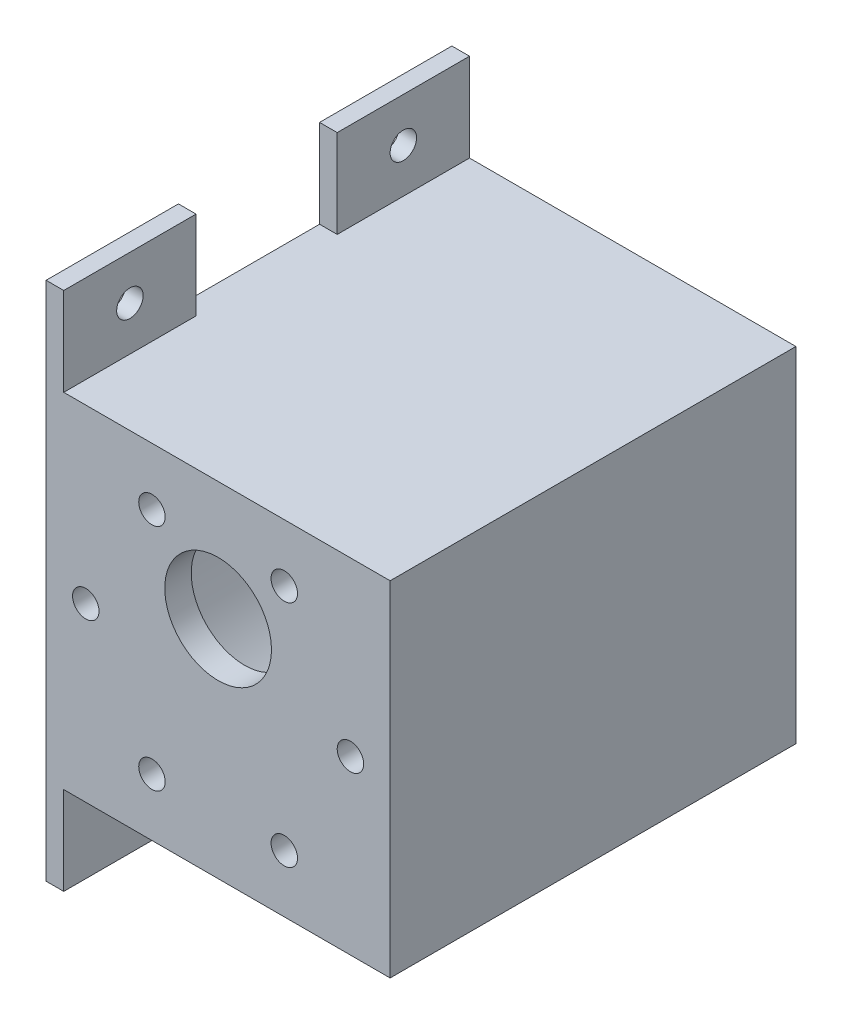
from build123d import *

# Parameters (mm, degrees)
SKETCH1_R           = 18.05
BOSS_EXTRUDE1_DEPTH = 3
SKETCH2_R           = 1.5
CUT_EXTRUDE1_DEPTH  = 3
CIRPATTERN1_COUNT   = 6
SKETCH3_R           = 6.05
CUT_EXTRUDE2_DEPTH  = 3
SKETCH4_W           = 39
SKETCH4_H           = 39
SKETCH4_R           = 18.05
BOSS_EXTRUDE2_DEPTH = 21
BOSS_EXTRUDE3_DEPTH = 25
SKETCH6_W           = 15
SKETCH6_H           = 10
SKETCH6_R           = 1.5
BOSS_EXTRUDE4_DEPTH = 2
SKETCH7_W           = 15
SKETCH7_H           = 10
SKETCH7_R           = 1.5
BOSS_EXTRUDE5_DEPTH = 2


with BuildPart() as part:
    # Sketch1 → Boss-Extrude1 (new body)
    with BuildSketch(Plane.XY):
        Circle(SKETCH1_R)
    extrude(amount=BOSS_EXTRUDE1_DEPTH)

    # Sketch2 → Cut-Extrude1 (cut)
    with BuildSketch(Plane.XY.offset(3)):
        with Locations((-15, 0)):
            Circle(SKETCH2_R)
    cut_extrude1 = extrude(amount=-CUT_EXTRUDE1_DEPTH, mode=Mode.SUBTRACT)

    # CirPattern1: Cut-Extrude1 ×6 about axis
    cirpattern1_axis = Axis((0, 0, 0), (0, 0, 1))
    for i in range(1, CIRPATTERN1_COUNT):
        add(cut_extrude1.rotate(cirpattern1_axis, i * 360 / CIRPATTERN1_COUNT), mode=Mode.SUBTRACT)

    # Sketch3 → Cut-Extrude2 (cut)
    with BuildSketch(Plane.XY.offset(3)):
        with Locations((0, 6)):
            Circle(SKETCH3_R)
    extrude(amount=-CUT_EXTRUDE2_DEPTH, mode=Mode.SUBTRACT)

    # Sketch4 → Boss-Extrude2 (add)
    with BuildSketch(Plane.XY.offset(3)):
        Rectangle(SKETCH4_W, SKETCH4_H)
        Circle(SKETCH4_R, mode=Mode.SUBTRACT)
    extrude(amount=-BOSS_EXTRUDE2_DEPTH)

    # Sketch5 → Boss-Extrude3 (add)
    with BuildSketch(Plane(origin=(0, 0, -18), x_dir=(-1, 0, 0), z_dir=(0, 0, -1))):
        with BuildLine():
            Line((0, 18.05), (19.5, 18.05))
            Line((19.5, 18.05), (19.5, 19.5))
            Line((19.5, 19.5), (-19.5, 19.5))
            Line((-19.5, 19.5), (-19.5, -19.5))
            Line((-19.5, -19.5), (19.5, -19.5))
            Line((19.5, -19.5), (19.5, -18.05))
            Line((19.5, -18.05), (0, -18.05))
            ThreePointArc((0, -18.05), (-18.05, 0), (0, 18.05))
        make_face()
    extrude(amount=BOSS_EXTRUDE3_DEPTH)

    # Sketch6 → Boss-Extrude4 (add)
    with BuildSketch(Plane.ZY.offset(19.5)):
        with Locations((-35.5, 24.5)):
            Rectangle(SKETCH6_W, SKETCH6_H)
        with Locations((-35.5, 24.5)):
            Circle(SKETCH6_R, mode=Mode.SUBTRACT)
        with Locations((-35.5, -24.5)):
            Rectangle(SKETCH6_W, SKETCH6_H)
        with Locations((-35.5, -24.5)):
            Circle(SKETCH6_R, mode=Mode.SUBTRACT)
    extrude(amount=-BOSS_EXTRUDE4_DEPTH)

    # Sketch7 → Boss-Extrude5 (add)
    with BuildSketch(Plane.ZY.offset(19.5)):
        with Locations((-4.5, 24.5)):
            Rectangle(SKETCH7_W, SKETCH7_H)
        with Locations((-4.5, 24.5)):
            Circle(SKETCH7_R, mode=Mode.SUBTRACT)
        with Locations((-4.5, -24.5)):
            Rectangle(SKETCH7_W, SKETCH7_H)
        with Locations((-4.5, -24.5)):
            Circle(SKETCH7_R, mode=Mode.SUBTRACT)
    extrude(amount=-BOSS_EXTRUDE5_DEPTH)


solid = part.part
